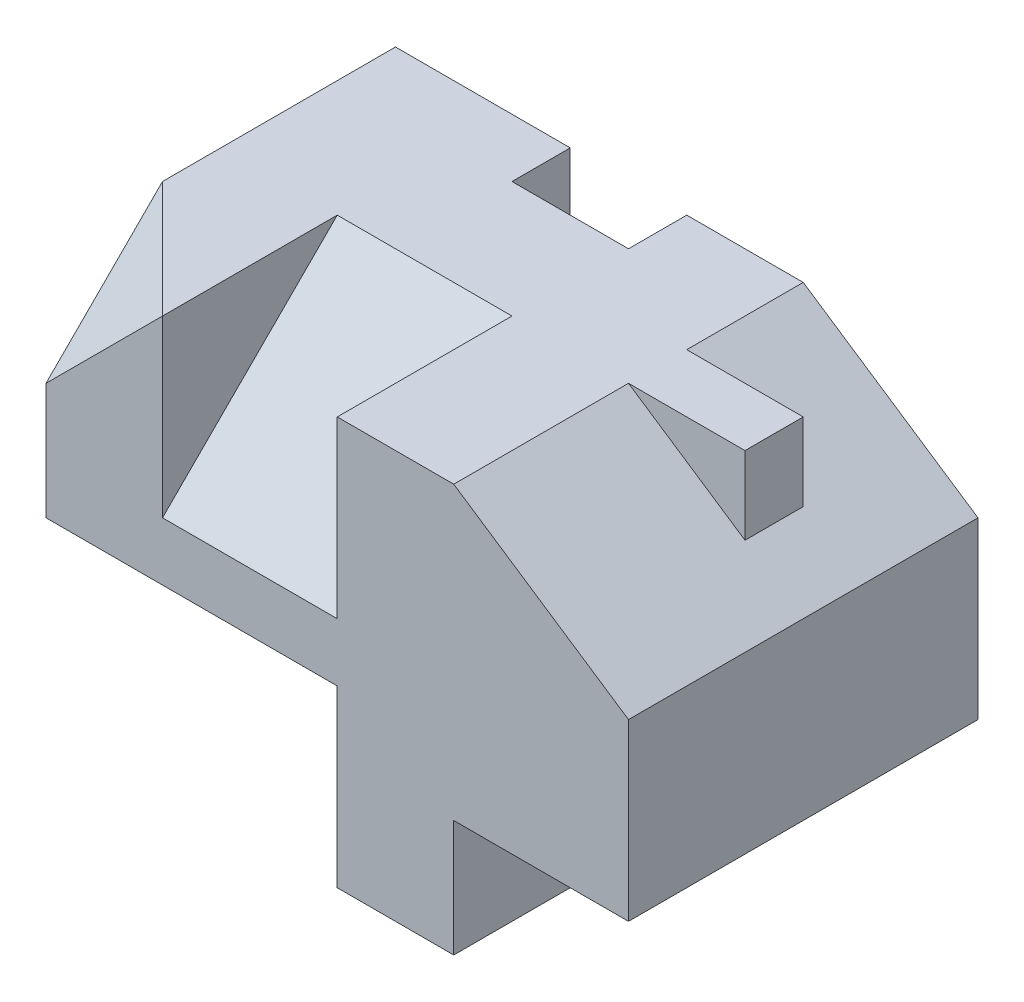
from build123d import *

# Parameters (mm, degrees)
BOSS_EXTRUDE1_DEPTH      = 3
BOSS_EXTRUDE2_DEPTH      = 4
CUT_EXTRUDE4_DEPTH       = 3
CUT_EXTRUDE5_DEPTH       = 3
BOSS_EXTRUDE3_DEPTH      = 5
BOSS_EXTRUDE3_DEPTH_BACK = 1
SKETCH7_W                = 2
SKETCH7_H                = 1
BOSS_EXTRUDE4_DEPTH      = 5


with BuildPart() as part:
    # Sketch2 → Boss-Extrude1 (new body)
    with BuildSketch(Plane(origin=(0, 0, 0), x_dir=(1, 0, 0), z_dir=(0, 1, 0))):
        Polygon((0, 0), (2, 0), (5, -5), (7, -5), (7, 2), (5, 2), (5, 0), (3, 0), (3, 2), (0, 2), align=None)
    extrude(amount=BOSS_EXTRUDE1_DEPTH)

    # Sketch3 → Boss-Extrude2 (add)
    with BuildSketch(Plane(origin=(0, 3, 0), x_dir=(1, 0, 0), z_dir=(0, 1, 0))):
        Polygon((3, 0), (3, 1), (0, 1), (0, 0), (2, 0), (5, -5), (7, -5), (7, 1), (5, 1), (5, 0), align=None)
        Polygon((2, 0), (0, 0), (0, -5), (5, -5), align=None)
    extrude(amount=BOSS_EXTRUDE2_DEPTH)

    # Sketch5 → Cut-Extrude4 (cut)
    with BuildSketch(Plane.ZY.offset(-5)):
        Polygon((5, 4), (5, 7), (2, 7), align=None)
    extrude(amount=CUT_EXTRUDE4_DEPTH, mode=Mode.SUBTRACT)

    # 3DSketch1 → Cut-Extrude5 (cut, along a direction that is not the sketch's normal)
    with BuildSketch(Plane(origin=(0, 5, 5), x_dir=(0, 0.7071067811865476, -0.7071067811865476), z_dir=(0.5773502691896267, -0.5773502691896254, -0.5773502691896254))):
        Polygon((0, 0), (1.414213562, 2.449489743), (2.828427125, 0), align=None)
    extrude(amount=-CUT_EXTRUDE5_DEPTH, dir=(1, 0, 0), mode=Mode.SUBTRACT)

    # Sketch6 → Boss-Extrude3 (add, two sides)
    with BuildSketch(Plane.XY) as boss_extrude3_sk:
        Polygon((7, 7), (10, 5), (10, 2), (7, 2), align=None)
    extrude(amount=BOSS_EXTRUDE3_DEPTH)
    extrude(boss_extrude3_sk.sketch, amount=-BOSS_EXTRUDE3_DEPTH_BACK)

    # Sketch7 → Boss-Extrude4 (add)
    with BuildSketch(Plane(origin=(0, 7, 0), x_dir=(1, 0, 0), z_dir=(0, 1, 0))):
        with Locations((8, -1.5)):
            Rectangle(SKETCH7_W, SKETCH7_H)
    extrude(amount=-BOSS_EXTRUDE4_DEPTH)


solid = part.part
